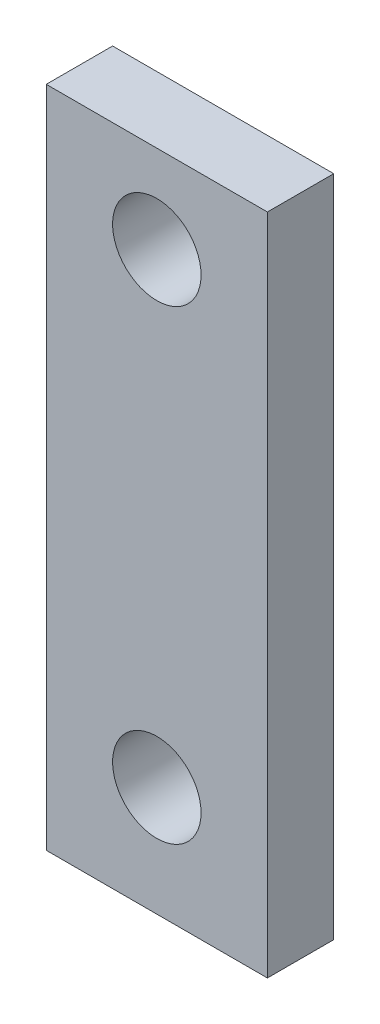
from build123d import *

# Parameters (mm, degrees)
SKETCH1_W           = 10
SKETCH1_H           = 30
BOSS_EXTRUDE1_DEPTH = 3
SKETCH2_R           = 2
CUT_EXTRUDE1_DEPTH  = 10


with BuildPart() as part:
    # Sketch1 → Boss-Extrude1 (new body)
    with BuildSketch(Plane.XY):
        Rectangle(SKETCH1_W, SKETCH1_H)
    extrude(amount=BOSS_EXTRUDE1_DEPTH)

    # Sketch2 → Cut-Extrude1 (cut)
    with BuildSketch(Plane.XY.offset(3)):
        with Locations((0, 11.028320769)):
            Circle(SKETCH2_R)
        with Locations((0, -10.034899621)):
            Circle(SKETCH2_R)
    extrude(amount=-CUT_EXTRUDE1_DEPTH, mode=Mode.SUBTRACT)


solid = part.part
